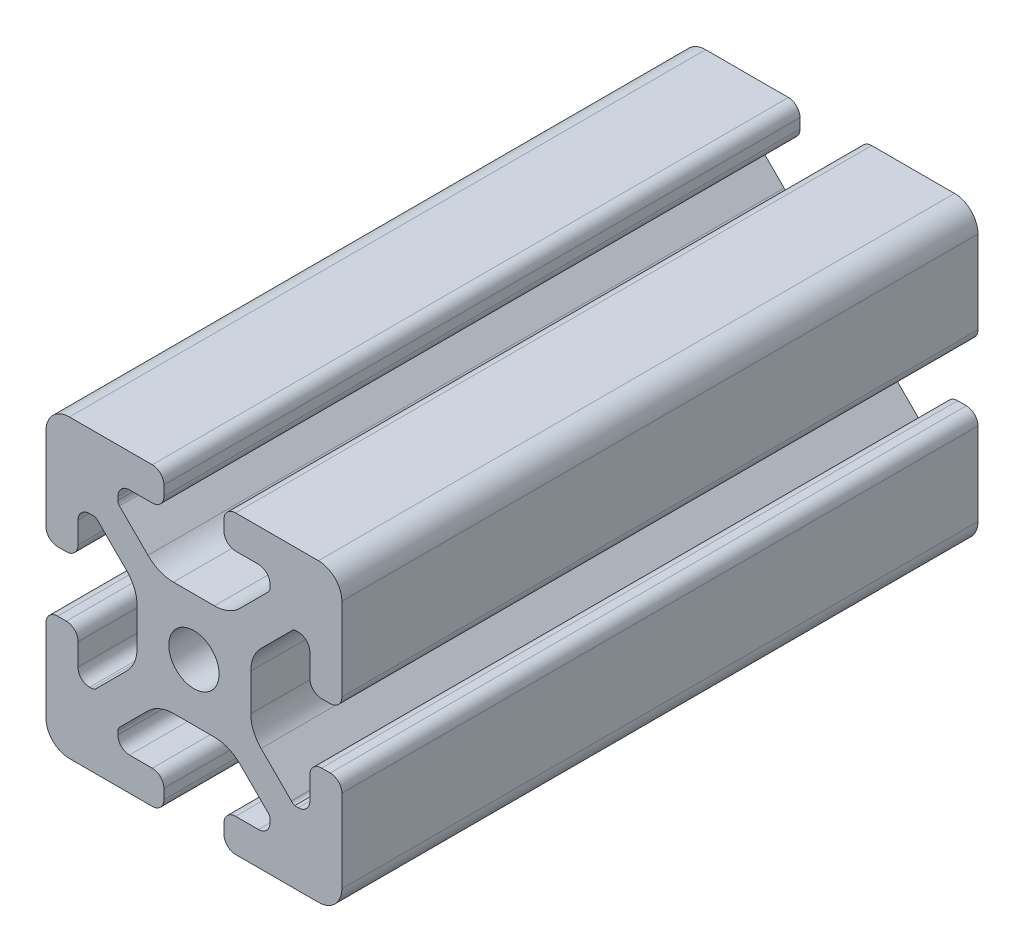
from build123d import *

# Parameters (mm, degrees)
SKETCH1_R      = 3.4
EXTRUDE1_DEPTH = 86


with BuildPart() as part:
    # Sketch1 → Extrude1 (new body)
    with BuildSketch(Plane.XY):
        with BuildLine():
            Line((-8.715, -15.524615034), (-5.63, -15.524615034))
            ThreePointArc((-5.63, -15.524615034), (-4.519842354, -15.984457388), (-4.06, -17.094615034))
            Line((-4.06, -17.094615034), (-4.06, -18.43))
            ThreePointArc((-4.06, -18.43), (-4.519842354, -19.540157646), (-5.63, -20))
            Line((-5.63, -20), (-16.674615034, -20))
            ThreePointArc((-16.674615034, -20), (-18.951578385, -19.194274381), (-20, -17.018368134))
            Line((-20, -17.018368134), (-20, -5.757918808))
            ThreePointArc((-20, -5.757918808), (-19.564709668, -4.603883664), (-18.43, -4.120449326))
            Line((-18.43, -4.120449326), (-17.25, -4.120449326))
            ThreePointArc((-17.25, -4.120449326), (-16.115287682, -4.60388249), (-15.67999625, -5.757919334))
            Line((-15.67999625, -5.757919334), (-15.67999625, -8.715399492))
            ThreePointArc((-15.67999625, -8.715399492), (-15.220153896, -9.825557139), (-14.10999625, -10.285399492))
            Line((-14.10999625, -10.285399492), (-13.816898819, -10.285399492))
            ThreePointArc((-13.816898819, -10.285399492), (-13.526061711, -10.227547119), (-13.279501941, -10.062800646))
            Line((-13.279501941, -10.062800646), (-9.076242789, -5.859541495))
            ThreePointArc((-9.076242789, -5.859541495), (-8.046572221, -4.318530588), (-7.685, -2.500784284))
            Line((-7.685, -2.500784284), (-7.685, 2.500784284))
            ThreePointArc((-7.685, 2.500784284), (-8.046572221, 4.318530588), (-9.076242789, 5.859541495))
            Line((-9.076242789, 5.859541495), (-13.040489136, 9.823787841))
            ThreePointArc((-13.040489136, 9.823787841), (-13.354224618, 10.012729352), (-13.71989919, 10.033001362))
            Line((-13.71989919, 10.033001362), (-14.05520779, 10.044710596))
            ThreePointArc((-14.05520779, 10.044710596), (-15.200613642, 9.605030484), (-15.68, 8.475666998))
            Line((-15.68, 8.475666998), (-15.68, 5.572979049))
            ThreePointArc((-15.68, 5.572979049), (-16.139842354, 4.462821403), (-17.25, 4.002979049))
            Line((-17.25, 4.002979049), (-18.43, 4.002979049))
            ThreePointArc((-18.43, 4.002979049), (-19.540157646, 4.462821403), (-20, 5.572979049))
            Line((-20, 5.572979049), (-20, 13.004526564))
            Line((-20, 13.004526564), (-20, 16.83))
            ThreePointArc((-20, 16.83), (-19.071528496, 19.071528496), (-16.83, 20))
            Line((-16.83, 20), (-5.63, 20))
            ThreePointArc((-5.63, 20), (-4.519842354, 19.540157646), (-4.06, 18.43))
            Line((-4.06, 18.43), (-4.06, 17.094615034))
            ThreePointArc((-4.06, 17.094615034), (-4.519842354, 15.984457388), (-5.63, 15.524615034))
            Line((-5.63, 15.524615034), (-8.715, 15.524615034))
            ThreePointArc((-8.715, 15.524615034), (-9.825157646, 15.06477268), (-10.285, 13.954615034))
            Line((-10.285, 13.954615034), (-10.285, 13.492503602))
            ThreePointArc((-10.285, 13.492503602), (-10.227148445, 13.201664194), (-10.062401154, 12.955102448))
            Line((-10.062401154, 12.955102448), (-6.217092793, 9.109794088))
            ThreePointArc((-6.217092793, 9.109794088), (-4.63891877, 8.055291919), (-2.777335583, 7.685))
            Line((-2.777335583, 7.685), (2.777335583, 7.685))
            ThreePointArc((2.777335583, 7.685), (4.63891877, 8.055291919), (6.217092793, 9.109794088))
            Line((6.217092793, 9.109794088), (10.062401154, 12.955102448))
            ThreePointArc((10.062401154, 12.955102448), (10.227148445, 13.201664194), (10.285, 13.492503602))
            Line((10.285, 13.492503602), (10.285, 13.954615034))
            ThreePointArc((10.285, 13.954615034), (9.825157646, 15.06477268), (8.715, 15.524615034))
            Line((8.715, 15.524615034), (5.63, 15.524615034))
            ThreePointArc((5.63, 15.524615034), (4.519842354, 15.984457388), (4.06, 17.094615034))
            Line((4.06, 17.094615034), (4.06, 18.43))
            ThreePointArc((4.06, 18.43), (4.519842354, 19.540157646), (5.63, 20))
            Line((5.63, 20), (12.979635074, 20))
            Line((12.979635074, 20), (16.83, 20))
            ThreePointArc((16.83, 20), (19.071528496, 19.071528496), (20, 16.83))
            Line((20, 16.83), (20, 13.001098436))
            Line((20, 13.001098436), (20, 5.63))
            ThreePointArc((20, 5.63), (19.540157461, 4.519842693), (18.43, 4.060000526))
            Line((18.43, 4.060000526), (17.24999625, 4.060000526))
            ThreePointArc((17.24999625, 4.060000526), (16.139838603, 4.519842879), (15.67999625, 5.630000526))
            Line((15.67999625, 5.630000526), (15.67999625, 8.715399492))
            ThreePointArc((15.67999625, 8.715399492), (15.220153896, 9.825557139), (14.10999625, 10.285399492))
            Line((14.10999625, 10.285399492), (13.816903094, 10.285399492))
            ThreePointArc((13.816903094, 10.285399492), (13.526063686, 10.227547937), (13.279501941, 10.062800646))
            Line((13.279501941, 10.062800646), (9.076242789, 5.859541495))
            ThreePointArc((9.076242789, 5.859541495), (8.046572221, 4.318530588), (7.685, 2.500784284))
            Line((7.685, 2.500784284), (7.685, -2.500784284))
            ThreePointArc((7.685, -2.500784284), (8.046572221, -4.318530588), (9.076242789, -5.859541495))
            Line((9.076242789, -5.859541495), (13.163657296, -9.946956002))
            ThreePointArc((13.163657296, -9.946956002), (13.35903797, -10.160433474), (13.6200547, -10.285399492))
            Line((13.6200547, -10.285399492), (14.10999625, -10.285399492))
            ThreePointArc((14.10999625, -10.285399492), (15.220153896, -9.825557139), (15.67999625, -8.715399492))
            Line((15.67999625, -8.715399492), (15.67999625, -5.630000526))
            ThreePointArc((15.67999625, -5.630000526), (16.139838603, -4.519842879), (17.24999625, -4.060000526))
            Line((17.24999625, -4.060000526), (18.43, -4.060000526))
            ThreePointArc((18.43, -4.060000526), (19.540157461, -4.519842693), (20, -5.63))
            Line((20, -5.63), (20, -16.83))
            ThreePointArc((20, -16.83), (19.071528496, -19.071528496), (16.83, -20))
            Line((16.83, -20), (13, -20))
            Line((13, -20), (5.63, -20))
            ThreePointArc((5.63, -20), (4.519842354, -19.540157646), (4.06, -18.43))
            Line((4.06, -18.43), (4.06, -17.094615034))
            ThreePointArc((4.06, -17.094615034), (4.519842354, -15.984457388), (5.63, -15.524615034))
            Line((5.63, -15.524615034), (8.715, -15.524615034))
            ThreePointArc((8.715, -15.524615034), (9.825157646, -15.06477268), (10.285, -13.954615034))
            Line((10.285, -13.954615034), (10.285, -13.492503602))
            ThreePointArc((10.285, -13.492503602), (10.227148445, -13.201664194), (10.062401154, -12.955102448))
            Line((10.062401154, -12.955102448), (6.217092793, -9.109794088))
            ThreePointArc((6.217092793, -9.109794088), (4.63891877, -8.055291919), (2.777335583, -7.685))
            Line((2.777335583, -7.685), (-2.777335583, -7.685))
            ThreePointArc((-2.777335583, -7.685), (-4.63891877, -8.055291919), (-6.217092793, -9.109794088))
            Line((-6.217092793, -9.109794088), (-10.062401154, -12.955102448))
            ThreePointArc((-10.062401154, -12.955102448), (-10.227148445, -13.201664194), (-10.285, -13.492503602))
            Line((-10.285, -13.492503602), (-10.285, -13.954615034))
            ThreePointArc((-10.285, -13.954615034), (-9.825157646, -15.06477268), (-8.715, -15.524615034))
        make_face()
        Circle(SKETCH1_R, mode=Mode.SUBTRACT)
    extrude(amount=-EXTRUDE1_DEPTH)


solid = part.part
